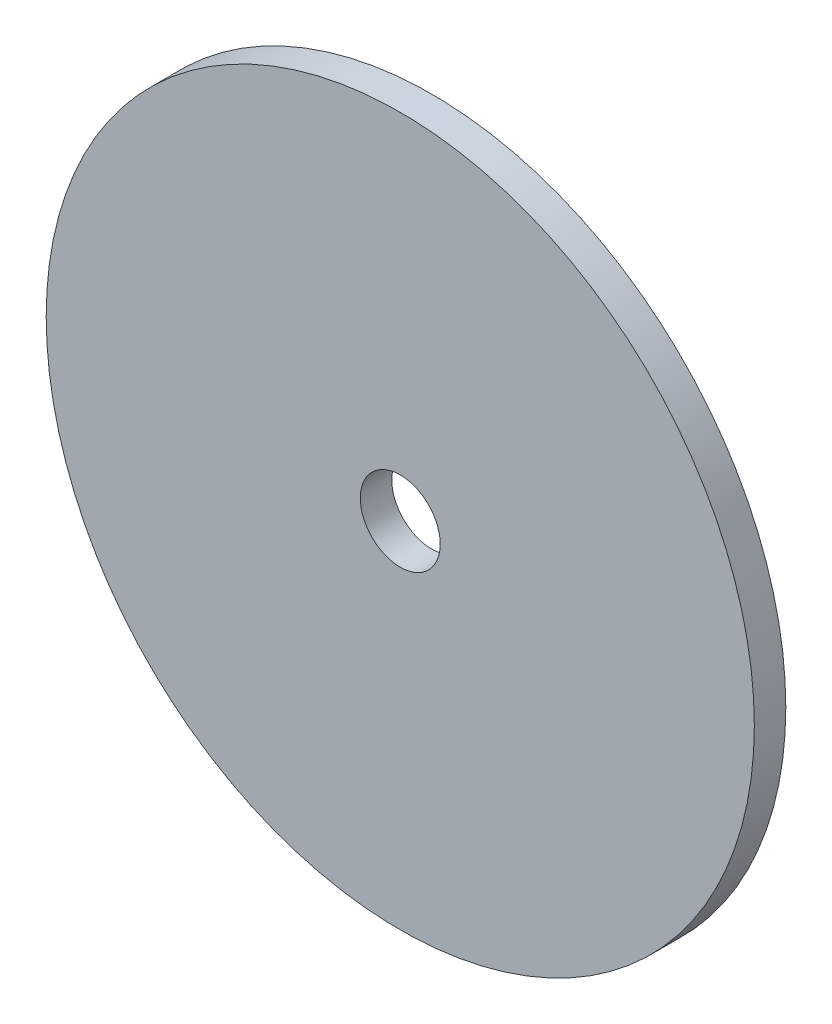
from build123d import *

# Parameters (mm, degrees)
SKETCH1_R           = 225
SKETCH1_R_2         = 25.4
BOSS_EXTRUDE1_DEPTH = 20


with BuildPart() as part:
    # Sketch1 → Boss-Extrude1 (new body)
    with BuildSketch(Plane.XY):
        Circle(SKETCH1_R)
        Circle(SKETCH1_R_2, mode=Mode.SUBTRACT)
    extrude(amount=BOSS_EXTRUDE1_DEPTH)


solid = part.part
